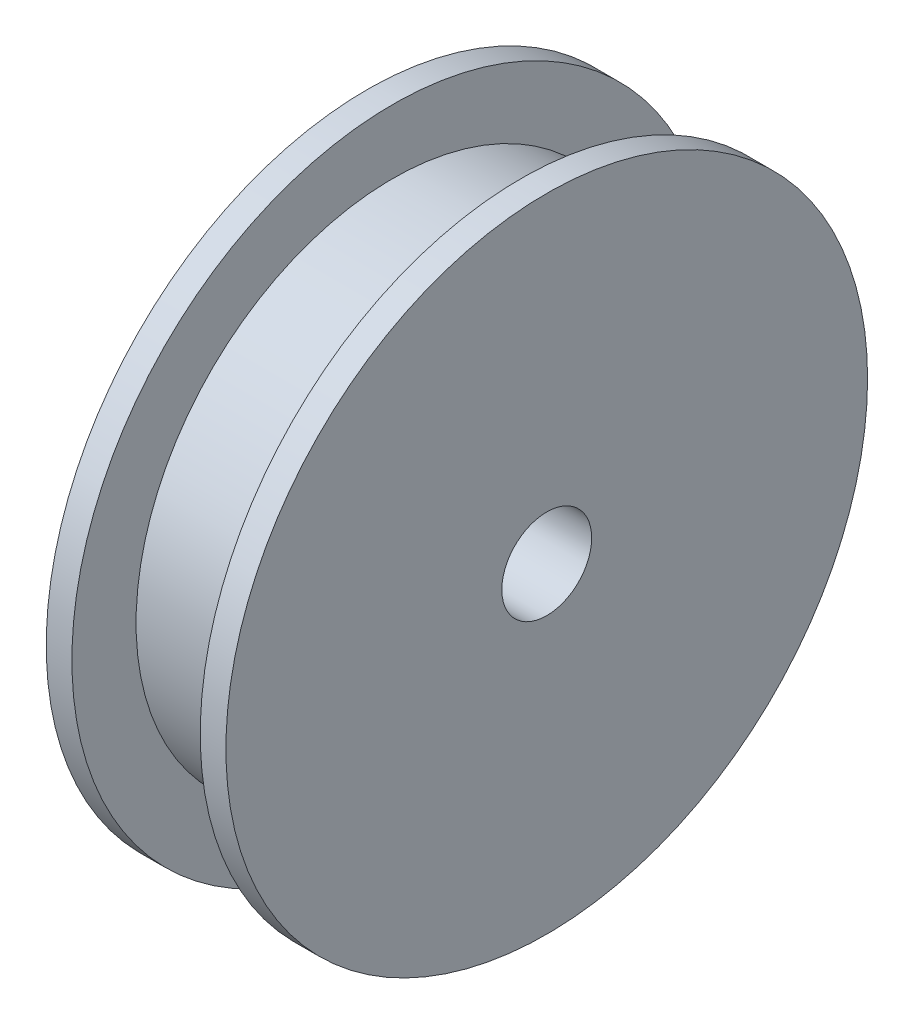
from build123d import *

# Parameters (mm, degrees)
SKETCH1_R           = 25
BOSS_EXTRUDE1_DEPTH = 2
SKETCH2_R           = 20
BOSS_EXTRUDE2_DEPTH = 10
SKETCH3_R           = 25
BOSS_EXTRUDE3_DEPTH = 2
SKETCH4_R           = 3.5
CUT_EXTRUDE1_DEPTH  = 19


with BuildPart() as part:
    # Sketch1 → Boss-Extrude1 (new body)
    with BuildSketch(Plane(origin=(0, 0, 0), x_dir=(0, 0, -1), z_dir=(1, 0, 0))):
        Circle(SKETCH1_R)
    extrude(amount=BOSS_EXTRUDE1_DEPTH)

    # Sketch2 → Boss-Extrude2 (add)
    with BuildSketch(Plane(origin=(2, 0, 0), x_dir=(0, 0, -1), z_dir=(1, 0, 0))):
        Circle(SKETCH2_R)
    extrude(amount=BOSS_EXTRUDE2_DEPTH)

    # Sketch3 → Boss-Extrude3 (add)
    with BuildSketch(Plane(origin=(12, 0, 0), x_dir=(0, 0, -1), z_dir=(1, 0, 0))):
        Circle(SKETCH3_R)
    extrude(amount=BOSS_EXTRUDE3_DEPTH)

    # Sketch4 → Cut-Extrude1 (cut)
    with BuildSketch(Plane.ZY):
        Circle(SKETCH4_R)
    extrude(amount=-CUT_EXTRUDE1_DEPTH, mode=Mode.SUBTRACT)


solid = part.part
